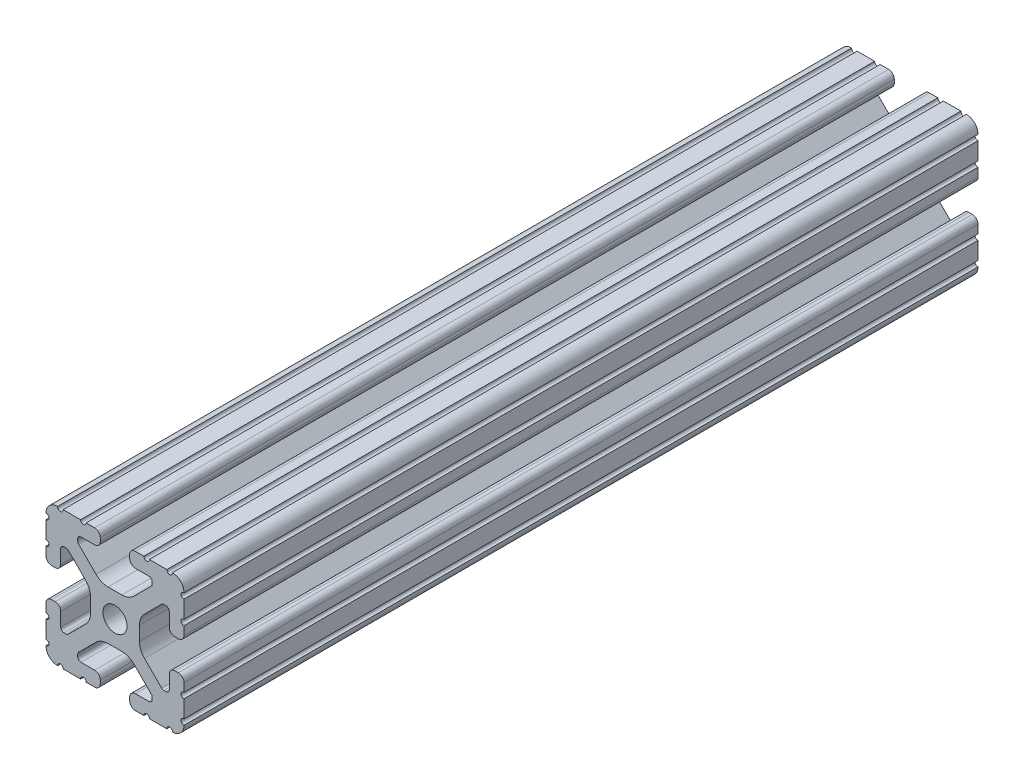
from build123d import *

# Parameters (mm, degrees)
SKETCH1_R               = 3.3274
BOSS_EXTRUDE1_DEPTH     = 609.6
SKETCH2_W               = 42.839593621
SKETCH2_H               = 1002.279512573
CUT_EXTRUDE1_DEPTH      = 5.334
CUT_EXTRUDE1_DEPTH_BACK = 41.148


with BuildPart() as part:
    # Sketch1 → Boss-Extrude1 (new body, symmetric)
    with BuildSketch(Plane.XY):
        with BuildLine():
            Line((-10.287, 13.552357131), (-10.287, 14.0843))
            ThreePointArc((-10.287, 14.0843), (-10.022898185, 14.721898185), (-9.3853, 14.986))
            Line((-9.3853, 14.986), (-5.617617549, 14.986))
            ThreePointArc((-5.617617549, 14.986), (-4.519044045, 15.441044045), (-4.064, 16.539617549))
            Line((-4.064, 16.539617549), (-4.064, 17.496382451))
            ThreePointArc((-4.064, 17.496382451), (-4.519044045, 18.594955955), (-5.617617549, 19.05))
            Line((-5.617617549, 19.05), (-7.974178704, 19.05))
            ThreePointArc((-7.974178704, 19.05), (-8.736178704, 18.288), (-9.498178704, 19.05))
            Line((-9.498178704, 19.05), (-14.327719207, 19.05))
            ThreePointArc((-14.327719207, 19.05), (-15.087603123, 18.231251131), (-15.847487039, 19.05))
            ThreePointArc((-15.847487039, 19.05), (-18.120176289, 18.120192083), (-19.05, 15.847509295))
            ThreePointArc((-19.05, 15.847509295), (-18.231250992, 15.08762539), (-19.05, 14.327741484))
            Line((-19.05, 14.327741484), (-19.05, 9.496091471))
            ThreePointArc((-19.05, 9.496091471), (-18.231250992, 8.736207565), (-19.05, 7.97632366))
            Line((-19.05, 7.97632366), (-19.05, 5.617617549))
            ThreePointArc((-19.05, 5.617617549), (-18.594955955, 4.519044045), (-17.496382451, 4.064))
            Line((-17.496382451, 4.064), (-16.539617549, 4.064))
            ThreePointArc((-16.539617549, 4.064), (-15.441044045, 4.519044045), (-14.986, 5.617617549))
            Line((-14.986, 5.617617549), (-14.986, 9.385342516))
            ThreePointArc((-14.986, 9.385342516), (-14.721898185, 10.022940701), (-14.0843, 10.287042516))
            Line((-14.0843, 10.287042516), (-13.516042086, 10.287042516))
            ThreePointArc((-13.516042086, 10.287042516), (-13.170975923, 10.218404478), (-12.878443117, 10.022939917))
            Line((-12.878443117, 10.022939917), (-8.14758008, 5.292065243))
            ThreePointArc((-8.14758008, 5.292065243), (-7.117955879, 3.751120653), (-6.7564, 1.933453584))
            Line((-6.7564, 1.933453584), (-6.7564, -1.933453584))
            ThreePointArc((-6.7564, -1.933453584), (-7.117955879, -3.751120653), (-8.14758008, -5.292065243))
            Line((-8.14758008, -5.292065243), (-12.878443117, -10.022939917))
            ThreePointArc((-12.878443117, -10.022939917), (-13.170975923, -10.218404478), (-13.516042086, -10.287042516))
            Line((-13.516042086, -10.287042516), (-14.0843, -10.287042516))
            ThreePointArc((-14.0843, -10.287042516), (-14.721898185, -10.022940701), (-14.986, -9.385342516))
            Line((-14.986, -9.385342516), (-14.986, -5.617617549))
            ThreePointArc((-14.986, -5.617617549), (-15.441044045, -4.519044045), (-16.539617549, -4.064))
            Line((-16.539617549, -4.064), (-17.496382451, -4.064))
            ThreePointArc((-17.496382451, -4.064), (-18.594955955, -4.519044045), (-19.05, -5.617617549))
            Line((-19.05, -5.617617549), (-19.05, -7.976318491))
            ThreePointArc((-19.05, -7.976318491), (-18.231250992, -8.736202396), (-19.05, -9.496086302))
            Line((-19.05, -9.496086302), (-19.05, -14.32774291))
            ThreePointArc((-19.05, -14.32774291), (-18.231250992, -15.087626816), (-19.05, -15.847510721))
            ThreePointArc((-19.05, -15.847510721), (-18.120175716, -18.120192644), (-15.847486868, -19.05))
            ThreePointArc((-15.847486868, -19.05), (-15.087602952, -18.231251131), (-14.327719036, -19.05))
            Line((-14.327719036, -19.05), (-9.496062448, -19.05))
            ThreePointArc((-9.496062448, -19.05), (-8.736178532, -18.231251131), (-7.976294616, -19.05))
            Line((-7.976294616, -19.05), (-5.617617549, -19.05))
            ThreePointArc((-5.617617549, -19.05), (-4.519044045, -18.594955955), (-4.064, -17.496382451))
            Line((-4.064, -17.496382451), (-4.064, -16.539617549))
            ThreePointArc((-4.064, -16.539617549), (-4.519044045, -15.441044045), (-5.617617549, -14.986))
            Line((-5.617617549, -14.986), (-9.3853, -14.986))
            ThreePointArc((-9.3853, -14.986), (-10.022898185, -14.721898185), (-10.287, -14.0843))
            Line((-10.287, -14.0843), (-10.287, -13.552357131))
            ThreePointArc((-10.287, -13.552357131), (-10.218362387, -13.207291992), (-10.022898969, -12.91475973))
            Line((-10.022898969, -12.91475973), (-5.252158105, -8.144007132))
            ThreePointArc((-5.252158105, -8.144007132), (-3.715177372, -7.117027388), (-1.902183975, -6.7564))
            Line((-1.902183975, -6.7564), (1.902183975, -6.7564))
            ThreePointArc((1.902183975, -6.7564), (3.715177372, -7.117027388), (5.252158105, -8.144007132))
            Line((5.252158105, -8.144007132), (10.022898969, -12.91475973))
            ThreePointArc((10.022898969, -12.91475973), (10.218362387, -13.207291992), (10.287, -13.552357131))
            Line((10.287, -13.552357131), (10.287, -14.0843))
            ThreePointArc((10.287, -14.0843), (10.022898185, -14.721898185), (9.3853, -14.986))
            Line((9.3853, -14.986), (5.617617549, -14.986))
            ThreePointArc((5.617617549, -14.986), (4.519044045, -15.441044045), (4.064, -16.539617549))
            Line((4.064, -16.539617549), (4.064, -17.496382451))
            ThreePointArc((4.064, -17.496382451), (4.519044045, -18.594955955), (5.617617549, -19.05))
            Line((5.617617549, -19.05), (7.976294616, -19.05))
            ThreePointArc((7.976294616, -19.05), (8.736178532, -18.231251131), (9.496062448, -19.05))
            Line((9.496062448, -19.05), (14.327719036, -19.05))
            ThreePointArc((14.327719036, -19.05), (15.087602952, -18.231251131), (15.847486868, -19.05))
            ThreePointArc((15.847486868, -19.05), (18.120175716, -18.120192644), (19.05, -15.847510721))
            ThreePointArc((19.05, -15.847510721), (18.231250992, -15.087626816), (19.05, -14.32774291))
            Line((19.05, -14.32774291), (19.05, -9.496086302))
            ThreePointArc((19.05, -9.496086302), (18.231250992, -8.736202396), (19.05, -7.976318491))
            Line((19.05, -7.976318491), (19.05, -5.617617549))
            ThreePointArc((19.05, -5.617617549), (18.594955955, -4.519044045), (17.496382451, -4.064))
            Line((17.496382451, -4.064), (16.539617549, -4.064))
            ThreePointArc((16.539617549, -4.064), (15.441044045, -4.519044045), (14.986, -5.617617549))
            Line((14.986, -5.617617549), (14.986, -9.385342516))
            ThreePointArc((14.986, -9.385342516), (14.721898185, -10.022940701), (14.0843, -10.287042516))
            Line((14.0843, -10.287042516), (13.516042086, -10.287042516))
            ThreePointArc((13.516042086, -10.287042516), (13.170975923, -10.218404478), (12.878443117, -10.022939917))
            Line((12.878443117, -10.022939917), (8.14758008, -5.292065243))
            ThreePointArc((8.14758008, -5.292065243), (7.117955879, -3.751120653), (6.7564, -1.933453584))
            Line((6.7564, -1.933453584), (6.7564, 1.933453584))
            ThreePointArc((6.7564, 1.933453584), (7.117955879, 3.751120653), (8.14758008, 5.292065243))
            Line((8.14758008, 5.292065243), (12.878443117, 10.022939917))
            ThreePointArc((12.878443117, 10.022939917), (13.170975923, 10.218404478), (13.516042086, 10.287042516))
            Line((13.516042086, 10.287042516), (14.0843, 10.287042516))
            ThreePointArc((14.0843, 10.287042516), (14.721898185, 10.022940701), (14.986, 9.385342516))
            Line((14.986, 9.385342516), (14.986, 5.617617549))
            ThreePointArc((14.986, 5.617617549), (15.441044045, 4.519044045), (16.539617549, 4.064))
            Line((16.539617549, 4.064), (17.496382451, 4.064))
            ThreePointArc((17.496382451, 4.064), (18.594955955, 4.519044045), (19.05, 5.617617549))
            Line((19.05, 5.617617549), (19.05, 7.97632366))
            ThreePointArc((19.05, 7.97632366), (18.231250992, 8.736207565), (19.05, 9.496091471))
            Line((19.05, 9.496091471), (19.05, 14.327741484))
            ThreePointArc((19.05, 14.327741484), (18.231250992, 15.08762539), (19.05, 15.847509295))
            ThreePointArc((19.05, 15.847509295), (18.120176289, 18.120192083), (15.847487039, 19.05))
            ThreePointArc((15.847487039, 19.05), (15.087603123, 18.231251131), (14.327719207, 19.05))
            Line((14.327719207, 19.05), (9.498178704, 19.05))
            ThreePointArc((9.498178704, 19.05), (8.736178704, 18.288), (7.974178704, 19.05))
            Line((7.974178704, 19.05), (5.617617549, 19.05))
            ThreePointArc((5.617617549, 19.05), (4.519044045, 18.594955955), (4.064, 17.496382451))
            Line((4.064, 17.496382451), (4.064, 16.539617549))
            ThreePointArc((4.064, 16.539617549), (4.519044045, 15.441044045), (5.617617549, 14.986))
            Line((5.617617549, 14.986), (9.3853, 14.986))
            ThreePointArc((9.3853, 14.986), (10.022898185, 14.721898185), (10.287, 14.0843))
            Line((10.287, 14.0843), (10.287, 13.552357131))
            ThreePointArc((10.287, 13.552357131), (10.218362387, 13.207291992), (10.022898969, 12.91475973))
            Line((10.022898969, 12.91475973), (5.252158105, 8.144007132))
            ThreePointArc((5.252158105, 8.144007132), (3.715177372, 7.117027388), (1.902183975, 6.7564))
            Line((1.902183975, 6.7564), (-1.902183975, 6.7564))
            ThreePointArc((-1.902183975, 6.7564), (-3.715177372, 7.117027388), (-5.252158105, 8.144007132))
            Line((-5.252158105, 8.144007132), (-10.022898969, 12.91475973))
            ThreePointArc((-10.022898969, 12.91475973), (-10.218362387, 13.207291992), (-10.287, 13.552357131))
        make_face()
        Circle(SKETCH1_R, mode=Mode.SUBTRACT)
    extrude(amount=BOSS_EXTRUDE1_DEPTH, both=True)

    # Sketch2 → Cut-Extrude1 (cut, two sides)
    with BuildSketch(Plane(origin=(0, 19.05, 0), x_dir=(1, 0, 0), z_dir=(0, 1, 0))) as cut_extrude1_sk:
        with Locations((0.328899923, 110.810732084)):
            Rectangle(SKETCH2_W, SKETCH2_H)
    extrude(amount=CUT_EXTRUDE1_DEPTH, mode=Mode.SUBTRACT)
    extrude(cut_extrude1_sk.sketch, amount=-CUT_EXTRUDE1_DEPTH_BACK, mode=Mode.SUBTRACT)


solid = part.part
